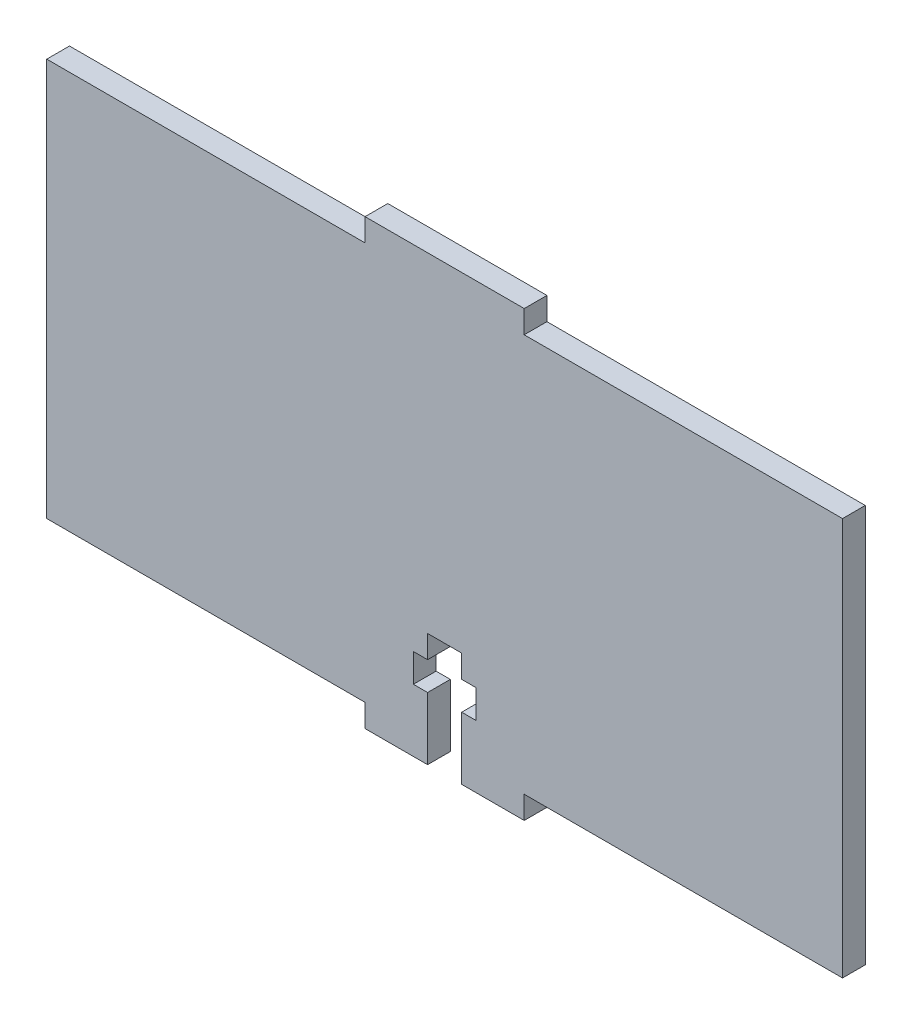
from build123d import *

# Parameters (mm, degrees)
MAIN_SLIDER_SIDE_DOWN_DEPTH = 2


with BuildPart() as part:
    # Sketch1 → Main Slider Side Down (new body)
    with BuildSketch(Plane.XY):
        Polygon((42, 35), (70, 35), (70, 0), (42, 0), (42, -2), (36.5, -2), (36.5, 3.5), (37.75, 3.5), (37.75, 6), (36.5, 6), (36.5, 8), (33.5, 8), (33.5, 6), (32.25, 6), (32.25, 3.5), (33.5, 3.5), (33.5, -2), (28, -2), (28, 0), (0, 0), (0, 35), (28, 35), (28, 37), (42, 37), align=None)
    extrude(amount=MAIN_SLIDER_SIDE_DOWN_DEPTH)


solid = part.part
